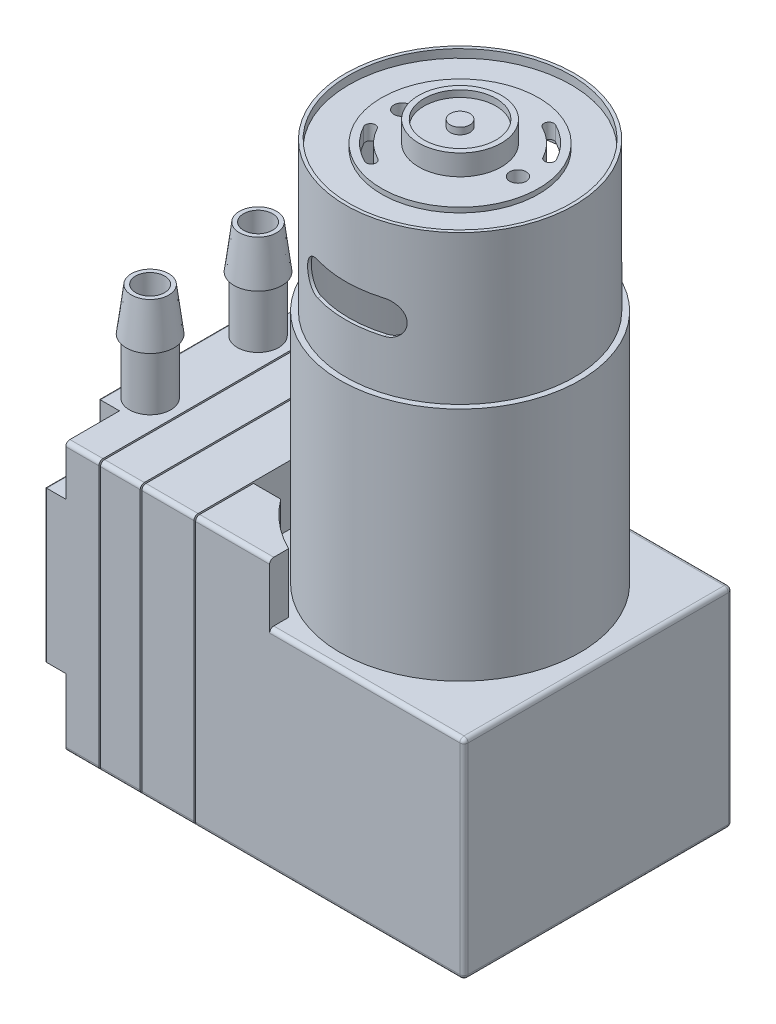
from build123d import *

# Parameters (mm, degrees)
ESBO_O1_W                  = 50.65
ESBO_O1_H                  = 32.45
RESSALTO_EXTRUS_O1_DEPTH   = 32.45
ESBO_O2_W                  = 23.5
ESBO_O2_H                  = 7.2
CORTE_EXTRUS_O1_DEPTH      = 32.45
ESBO_O3_W                  = 32.45
ESBO_O3_H                  = 32.45
ESBO_O3_W_2                = 32.05
ESBO_O3_H_2                = 32.05
CORTE_EXTRUS_O2_DEPTH      = 0.2
ESBO_O4_W                  = 32.45
ESBO_O4_H                  = 32.45
ESBO_O4_W_2                = 32.05
ESBO_O4_H_2                = 32.05
CORTE_EXTRUS_O3_DEPTH      = 0.2
ESBO_O5_W                  = 32.45
ESBO_O5_H                  = 32.45
ESBO_O5_W_2                = 32.05
ESBO_O5_H_2                = 32.05
CORTE_EXTRUS_O4_DEPTH      = 0.2
CORTE_EXTRUS_O5_DEPTH      = 2.5
FILETE1_R                  = 0.2
FILETE2_R                  = 0.5
ESBO_O7_R                  = 15.5
CORTE_EXTRUS_O6_DEPTH      = 66.237929918
CORTE_EXTRUS_O7_DEPTH      = 7.2
RESSALTO_EXTRUS_O2_DEPTH   = 28.5
ESBO_O10_R                 = 13.825
RESSALTO_EXTRUS_O3_DEPTH   = 18
ESBO_O11_R                 = 13.425
CORTE_EXTRUS_O8_DEPTH      = 1
ESBO_O12_R                 = 9.5
RESSALTO_EXTRUS_O4_DEPTH   = 0.6
ESBO_O13_R                 = 5
ESBO_O13_R_2               = 4.35
ESBO_O13_R_3               = 1.19
RESSALTO_EXTRUS_O5_DEPTH   = 2.5
ESBO_O14_R                 = 4.35
ESBO_O14_R_2               = 1.19
RESSALTO_EXTRUS_O6_DEPTH   = 1.7
ESBO_O15_R                 = 1
CORTE_EXTRUS_O9_DEPTH      = 93.865426828
CORTE_EXTRUS_O9_DEPTH_BACK = 10.15
CORTE_EXTRUS_O10_DEPTH     = 96.248346442
ESBO_O17_R                 = 13.425
CORTE_EXTRUS_O11_DEPTH     = 44.3
RESSALTO_EXTRUS_O7_DEPTH   = 0.15
ESBO_O20_R                 = 1.7
CORTE_EXTRUS_O12_DEPTH     = 2


with BuildPart() as part:
    # Esboço1 → Ressalto-extrusão1 (new body)
    with BuildSketch(Plane(origin=(0, 0, 0), x_dir=(1, 0, 0), z_dir=(0, 1, 0))):
        with Locations((25.325, 16.225)):
            Rectangle(ESBO_O1_W, ESBO_O1_H)
    extrude(amount=RESSALTO_EXTRUS_O1_DEPTH)

    # Esboço2 → Corte-extrusão1 (cut)
    with BuildSketch(Plane.XY):
        with Locations((38.9, 28.85)):
            Rectangle(ESBO_O2_W, ESBO_O2_H)
    extrude(amount=-CORTE_EXTRUS_O1_DEPTH, mode=Mode.SUBTRACT)

    # Esboço3 → Corte-extrusão2 (cut)
    with BuildSketch(Plane(origin=(18.2, 0, 0), x_dir=(0, 0, -1), z_dir=(1, 0, 0))):
        with Locations((16.225, 16.225)):
            Rectangle(ESBO_O3_W, ESBO_O3_H)
        with Locations((16.225, 16.225)):
            Rectangle(ESBO_O3_W_2, ESBO_O3_H_2, mode=Mode.SUBTRACT)
    extrude(amount=-CORTE_EXTRUS_O2_DEPTH, mode=Mode.SUBTRACT)

    # Esboço4 → Corte-extrusão3 (cut)
    with BuildSketch(Plane.ZY.offset(-11.5)):
        with Locations((-16.225, 16.225)):
            Rectangle(ESBO_O4_W, ESBO_O4_H)
        with Locations((-16.225, 16.225)):
            Rectangle(ESBO_O4_W_2, ESBO_O4_H_2, mode=Mode.SUBTRACT)
    extrude(amount=-CORTE_EXTRUS_O3_DEPTH, mode=Mode.SUBTRACT)

    # Esboço5 → Corte-extrusão4 (cut)
    with BuildSketch(Plane.ZY.offset(-6.5)):
        with Locations((-16.225, 16.225)):
            Rectangle(ESBO_O5_W, ESBO_O5_H)
        with Locations((-16.225, 16.225)):
            Rectangle(ESBO_O5_W_2, ESBO_O5_H_2, mode=Mode.SUBTRACT)
    extrude(amount=-CORTE_EXTRUS_O4_DEPTH, mode=Mode.SUBTRACT)

    # Esboço6 → Corte-extrusão5 (cut)
    with BuildSketch(Plane.ZY):
        with BuildLine():
            Line((-32.45, 8.2), (-28.95, 8.2))
            ThreePointArc((-28.95, 8.2), (-26.828679656, 7.321320344), (-25.95, 5.2))
            Line((-25.95, 5.2), (-25.95, 0))
            Line((-25.95, 0), (-32.45, 0))
            Line((-32.45, 0), (-32.45, 8.2))
        make_face()
        with BuildLine():
            Line((0, 0), (0, 8.2))
            Line((0, 8.2), (-3.5, 8.2))
            ThreePointArc((-3.5, 8.2), (-5.621320344, 7.321320344), (-6.5, 5.2))
            Line((-6.5, 5.2), (-6.5, 0))
            Line((-6.5, 0), (0, 0))
        make_face()
        with BuildLine():
            Line((-32.45, 32.45), (-32.45, 26.45))
            Line((-32.45, 26.45), (-28.95, 26.45))
            ThreePointArc((-28.95, 26.45), (-26.828679656, 27.328679656), (-25.95, 29.45))
            Line((-25.95, 29.45), (-25.95, 32.45))
            Line((-25.95, 32.45), (-32.45, 32.45))
        make_face()
        with BuildLine():
            Line((-6.5, 32.45), (0, 32.45))
            Line((0, 32.45), (0, 26.45))
            Line((0, 26.45), (-3.5, 26.45))
            ThreePointArc((-3.5, 26.45), (-5.621320344, 27.328679656), (-6.5, 29.45))
            Line((-6.5, 29.45), (-6.5, 32.45))
        make_face()
    extrude(amount=-CORTE_EXTRUS_O5_DEPTH, mode=Mode.SUBTRACT)

    # Filete1
    filete1_edges = [part.edges().sort_by_distance(p)[0] for p in [
        (0, 17.325, -32.45),
        (0, 17.325, 0),
        (0, 0, -16.225),
        (0, 32.45, -16.225),
        (0, 7.321320344, -5.621320344),
        (0, 2.6, -6.5),
        (0, 8.2, -1.75),
        (0, 26.45, -30.7),
        (0, 27.328679656, -26.828679656),
        (0, 30.95, -25.95),
        (0, 27.328679656, -5.621320344),
        (0, 26.45, -1.75),
        (0, 30.95, -6.5),
        (0, 2.6, -25.95),
        (0, 7.321320344, -26.828679656),
        (0, 8.2, -30.7),
    ]]
    fillet(filete1_edges, radius=FILETE1_R)

    # Filete2
    filete2_edges = [part.edges().sort_by_distance(p)[0] for p in [
        (4.5, 0, 0),
        (4.5, 32.45, 0),
        (22.675, 32.45, -32.45),
        (50.65, 12.625, -32.45),
        (50.65, 12.625, 0),
        (38.9, 25.25, -32.45),
        (50.65, 25.25, -16.225),
        (38.9, 25.25, 0),
        (14.85, 0, -32.45),
        (34.425, 0, 0),
        (22.675, 32.45, 0),
        (14.85, 32.45, -32.45),
        (18.1, 32.25, -0.2),
        (18.1, 32.25, -32.25),
        (18.1, 0.2, -32.25),
        (18.1, 0.2, -0.2),
        (34.425, 0, -32.45),
        (50.65, 0, -16.225),
        (14.85, 32.45, 0),
        (14.85, 0, 0),
        (9.1, 0, -32.45),
        (9.1, 32.45, -32.45),
        (11.6, 0.2, -0.2),
        (11.6, 0.2, -32.25),
        (11.6, 32.25, -32.25),
        (11.6, 32.25, -0.2),
        (9.1, 32.45, 0),
        (4.5, 32.45, -32.45),
        (9.1, 0, 0),
        (4.5, 0, -32.45),
        (6.6, 0.2, -0.2),
        (6.6, 0.2, -32.25),
        (6.6, 32.25, -32.25),
        (6.6, 32.25, -0.2),
    ]]
    fillet(filete2_edges, radius=FILETE2_R)

    # Esboço7 → Corte-extrusão6 (cut, through all)
    with BuildSketch(Plane(origin=(0, 25.25, 0), x_dir=(1, 0, 0), z_dir=(0, 1, 0))):
        with Locations((33.95, 16.225)):
            Circle(ESBO_O7_R)
    extrude(amount=CORTE_EXTRUS_O6_DEPTH, mode=Mode.SUBTRACT)

    # Esboço8 → Corte-extrusão7 (cut)
    with BuildSketch(Plane(origin=(0, 32.45, 0), x_dir=(1, 0, 0), z_dir=(0, 1, 0))):
        with BuildLine():
            Line((21.494102802, 25.45), (18, 25.45))
            Line((18, 25.45), (18, 7))
            Line((18, 7), (21.494102802, 7))
            ThreePointArc((21.494102802, 7), (18.45, 16.225), (21.494102802, 25.45))
        make_face()
    extrude(amount=-CORTE_EXTRUS_O7_DEPTH, mode=Mode.SUBTRACT)

    # Esboço9 → Ressalto-extrusão2 (add)
    with BuildSketch(Plane(origin=(0, 25.25, 0), x_dir=(1, 0, 0), z_dir=(0, 1, 0))):
        with BuildLine():
            Line((20.289289916, 18.35), (19.606556376, 18.35))
            ThreePointArc((19.606556376, 18.35), (48.45, 16.225), (19.606556376, 14.1))
            Line((19.606556376, 14.1), (20.289289916, 14.1))
            ThreePointArc((20.289289916, 14.1), (20.125, 16.225), (20.289289916, 18.35))
        make_face()
    extrude(amount=RESSALTO_EXTRUS_O2_DEPTH)

    # Esboço10 → Ressalto-extrusão3 (add)
    with BuildSketch(Plane(origin=(0, 53.75, 0), x_dir=(1, 0, 0), z_dir=(0, 1, 0))):
        with Locations(Location((33.95, 16.225, 0), (0, 0, 188.841817237))):
            Circle(ESBO_O10_R)
    extrude(amount=RESSALTO_EXTRUS_O3_DEPTH)

    # Esboço11 → Corte-extrusão8 (cut)
    with BuildSketch(Plane(origin=(0, 71.75, 0), x_dir=(1, 0, 0), z_dir=(0, 1, 0))):
        with Locations(Location((33.95, 16.225, 0), (0, 0, 180))):
            Circle(ESBO_O11_R)
    extrude(amount=-CORTE_EXTRUS_O8_DEPTH, mode=Mode.SUBTRACT)

    # Esboço12 → Ressalto-extrusão4 (add)
    with BuildSketch(Plane(origin=(0, 70.75, 0), x_dir=(1, 0, 0), z_dir=(0, 1, 0))):
        with Locations(Location((33.95, 16.225, 0), (0, 0, 180))):
            Circle(ESBO_O12_R)
    extrude(amount=RESSALTO_EXTRUS_O4_DEPTH)

    # Esboço13 → Ressalto-extrusão5 (add)
    with BuildSketch(Plane(origin=(0, 71.35, 0), x_dir=(1, 0, 0), z_dir=(0, 1, 0))):
        with Locations(Location((33.95, 16.225, 0), (0, 0, 270))):
            Circle(ESBO_O13_R)
        with Locations(Location((33.95, 16.225, 0), (0, 0, 270))):
            Circle(ESBO_O13_R_2, mode=Mode.SUBTRACT)
        with Locations(Location((33.95, 16.225, 0), (0, 0, 270))):
            Circle(ESBO_O13_R_3)
    extrude(amount=RESSALTO_EXTRUS_O5_DEPTH)

    # Esboço14 → Ressalto-extrusão6 (add)
    with BuildSketch(Plane(origin=(0, 71.35, 0), x_dir=(1, 0, 0), z_dir=(0, 1, 0))):
        with Locations(Location((33.95, 16.225, 0), (0, 0, 270))):
            Circle(ESBO_O14_R)
        with Locations(Location((33.95, 16.225, 0), (0, 0, 270))):
            Circle(ESBO_O14_R_2, mode=Mode.SUBTRACT)
    extrude(amount=RESSALTO_EXTRUS_O6_DEPTH)

    # Esboço15 → Corte-extrusão9 (cut, two sides)
    with BuildSketch(Plane(origin=(0, 70.75, 0), x_dir=(1, 0, 0), z_dir=(0, 1, 0))) as corte_extrus_o9_sk:
        with Locations(Location((26.95, 16.225, 0), (0, 0, 180))):
            Circle(ESBO_O15_R)
        with Locations(Location((40.95, 16.225, 0), (0, 0, 180))):
            Circle(ESBO_O15_R)
        with BuildLine():
            ThreePointArc((30.082215444, 8.543838458), (27.956020227, 10.05797426), (26.382, 12.140226322))
            ThreePointArc((26.382, 12.140226322), (26.62501579, 12.953210532), (27.438, 12.710194742))
            ThreePointArc((27.438, 12.710194742), (28.792389498, 10.918489479), (30.621906312, 9.615628441))
            ThreePointArc((30.621906312, 9.615628441), (30.88795587, 8.809888015), (30.082215444, 8.543838458))
        make_face()
        with BuildLine():
            ThreePointArc((41.518, 20.309773678), (39.943979773, 22.39202574), (37.817784556, 23.906161542))
            ThreePointArc((37.817784556, 23.906161542), (37.01204413, 23.640111985), (37.278093688, 22.834371559))
            ThreePointArc((37.278093688, 22.834371559), (39.107610502, 21.531510521), (40.462, 19.739805258))
            ThreePointArc((40.462, 19.739805258), (41.27498421, 19.496789468), (41.518, 20.309773678))
        make_face()
    extrude(amount=CORTE_EXTRUS_O9_DEPTH, mode=Mode.SUBTRACT)
    extrude(corte_extrus_o9_sk.sketch, amount=-CORTE_EXTRUS_O9_DEPTH_BACK, mode=Mode.SUBTRACT)

    # Esboço16 → Corte-extrusão10 (cut, through all)
    with BuildSketch(Plane.XY):
        with BuildLine():
            Line((29.993487882, 63.75), (37.993487882, 63.75))
            ThreePointArc((37.993487882, 63.75), (39.993487882, 61.75), (37.993487882, 59.75))
            Line((37.993487882, 59.75), (29.993487882, 59.75))
            ThreePointArc((29.993487882, 59.75), (27.993487882, 61.75), (29.993487882, 63.75))
        make_face()
    extrude(amount=-CORTE_EXTRUS_O10_DEPTH, mode=Mode.SUBTRACT)

    # Esboço17 → Corte-extrusão11 (cut)
    with BuildSketch(Plane(origin=(0, 25.25, 0), x_dir=(1, 0, 0), z_dir=(0, 1, 0))):
        with Locations(Location((33.95, 16.225, 0), (0, 0, 180))):
            Circle(ESBO_O17_R)
    extrude(amount=CORTE_EXTRUS_O11_DEPTH, mode=Mode.SUBTRACT)

    # Esboço18 → Revolução1 (revolve)
    with BuildSketch(Plane.ZY.offset(-3), mode=Mode.PRIVATE) as revolu_o1_sk:
        Polygon((-7.2, 32.45), (-7.2, 39.15), (-6.8, 39.15), (-7.45, 44.35), (-7.95, 44.35), (-7.95, 32.45), align=None)
    revolu_o1 = revolve(revolu_o1_sk.sketch.rotate(Axis((3, 32.45, -9.7), (0, 1, 0)), 180), axis=Axis((3, 32.45, -9.7), (0, 1, 0)))

    # Espelhar1: Revolução1 across plane
    add(revolu_o1.mirror(Plane.XY.offset(-16.225)))

    # Esboço19 → Ressalto-extrusão7 (add)
    with BuildSketch(Plane.ZY):
        Polygon((-24, 28.284936491), (-21.5, 28.284936491), (-22.75, 30.45), align=None)
        Polygon((-10.95, 30.45), (-8.45, 30.45), (-9.7, 28.284936491), align=None)
    extrude(amount=RESSALTO_EXTRUS_O7_DEPTH)

    # Esboço20 → Corte-extrusão12 (cut)
    with BuildSketch(Plane.XZ):
        with Locations(Location((34.175, -16.225, 0), (0, 0, 270))):
            Circle(ESBO_O20_R)
    extrude(amount=-CORTE_EXTRUS_O12_DEPTH, mode=Mode.SUBTRACT)


solid = part.part
